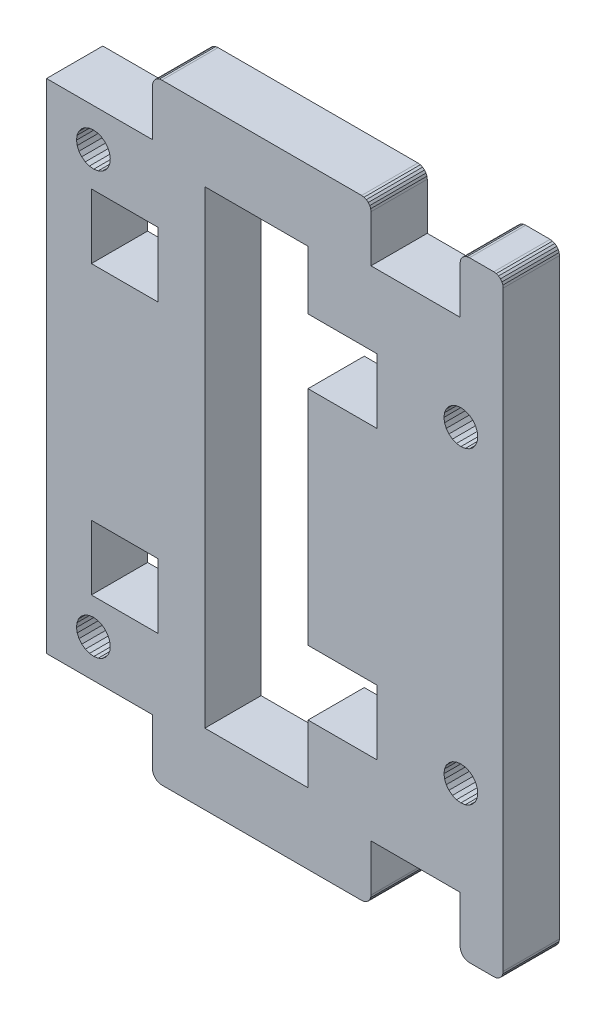
from build123d import *

# Parameters (mm, degrees)
SKETCH1_W           = 7.1
SKETCH1_H           = 6.9
BOSS_EXTRUDE1_DEPTH = 6


with BuildPart() as part:
    # Sketch1 → Boss-Extrude1 (new body)
    with BuildSketch(Plane.XY):
        Polygon((-358.994880286, -293.50655928), (-358.753699331, -293.406658857), (-358.494880286, -293.372584684), (-355.895187501, -293.372584684), (-355.636368456, -293.406658857), (-355.395187501, -293.50655928), (-355.18808072, -293.665477903), (-355.029162097, -293.872584684), (-354.929261675, -294.113765639), (-354.895187501, -294.372584684), (-354.899121361, -357.473371332), (-354.933365099, -357.732036876), (-355.033357982, -357.973038786), (-355.192292447, -358.179969532), (-355.399348154, -358.338741166), (-355.640428649, -358.438544435), (-355.899121051, -358.472584684), (-358.493457382, -358.472584684), (-358.752276427, -358.43851051), (-358.993457382, -358.338610088), (-359.200564163, -358.179691465), (-359.359482786, -357.972584684), (-359.459383208, -357.731403729), (-359.493457382, -357.472584684), (-359.493457382, -352.472584684), (-368.993457382, -352.472584684), (-368.993457382, -357.472584684), (-369.027531556, -357.731403729), (-369.127431978, -357.972584684), (-369.286350601, -358.179691465), (-369.493457382, -358.338610088), (-369.734638337, -358.43851051), (-369.993457382, -358.472584684), (-391.293457382, -358.472584684), (-391.552276427, -358.43851051), (-391.793457382, -358.338610088), (-392.000564163, -358.179691465), (-392.159482786, -357.972584684), (-392.259383208, -357.731403729), (-392.293457382, -357.472584684), (-392.293457382, -352.472584684), (-403.593457382, -352.472584684), (-403.593457382, -299.372584684), (-392.293457382, -299.372584684), (-392.293457382, -294.372584684), (-392.259383208, -294.113765639), (-392.159482786, -293.872584684), (-392.000564163, -293.665477903), (-391.793457382, -293.50655928), (-391.552276427, -293.406658857), (-391.293457382, -293.372584684), (-369.993457382, -293.372584684), (-369.734638337, -293.406658857), (-369.493457382, -293.50655928), (-369.286350601, -293.665477903), (-369.127431978, -293.872584684), (-369.027531556, -294.113765639), (-368.993457382, -294.372584684), (-368.993457382, -299.372584684), (-359.494880286, -299.372584684), (-359.494880286, -294.372584684), (-359.460806112, -294.113765639), (-359.36090569, -293.872584684), (-359.201987067, -293.665477903), align=None)
        Polygon((-357.610920971, -342.372584684), (-357.672254484, -342.838458965), (-357.852075244, -343.272584684), (-358.138128765, -343.64537689), (-358.510920971, -343.931430411), (-358.94504669, -344.111251171), (-359.410920971, -344.172584684), (-359.876795252, -344.111251171), (-360.310920971, -343.931430411), (-360.683713177, -343.64537689), (-360.969766698, -343.272584684), (-361.149587458, -342.838458965), (-361.210920971, -342.372584684), (-361.149587458, -341.906710403), (-360.969766698, -341.472584684), (-360.683713177, -341.099792478), (-360.310920971, -340.813738957), (-359.876795252, -340.633918196), (-359.410920971, -340.572584684), (-358.94504669, -340.633918196), (-358.510920971, -340.813738957), (-358.138128765, -341.099792478), (-357.852075244, -341.472584684), (-357.672254484, -341.906710403), align=None, mode=Mode.SUBTRACT)
        Polygon((-397.058387805, -347.482605219), (-396.867409445, -347.911939484), (-396.7940584, -348.376073376), (-396.843333421, -348.843376937), (-397.011876498, -349.282004201), (-397.288201699, -349.662063445), (-397.653477917, -349.95765426), (-398.082812183, -350.148632621), (-398.546946075, -350.221983666), (-399.014249636, -350.172708645), (-399.4528769, -350.004165568), (-399.832936144, -349.727840367), (-400.128526959, -349.362564149), (-400.319505319, -348.933229883), (-400.392856365, -348.469095991), (-400.343581343, -348.00179243), (-400.175038266, -347.563165166), (-399.898713066, -347.183105922), (-399.533436847, -346.887515107), (-399.104102582, -346.696536747), (-398.63996869, -346.623185701), (-398.172665129, -346.672460723), (-397.734037865, -346.8410038), (-397.35397862, -347.117329), align=None, mode=Mode.SUBTRACT)
        with Locations((-395.260918473, -310.622584684)):
            Rectangle(SKETCH1_W, SKETCH1_H, mode=Mode.SUBTRACT)
        Polygon((-375.710923469, -337.772584684), (-368.342459311, -337.772584684), (-368.342459311, -344.672584684), (-375.710923469, -344.672584684), (-375.710923469, -350.922574533), (-386.710918473, -350.922574533), (-386.710918473, -300.922594835), (-375.710923469, -300.922594835), (-375.710923469, -307.172584684), (-368.342459311, -307.172584684), (-368.342459311, -314.072584684), (-375.710923469, -314.072584684), align=None, mode=Mode.SUBTRACT)
        Polygon((-358.138128765, -310.74537689), (-358.510920971, -311.031430411), (-358.94504669, -311.211251171), (-359.410920971, -311.272584684), (-359.876795252, -311.211251171), (-360.310920971, -311.031430411), (-360.683713177, -310.74537689), (-360.969766698, -310.372584684), (-361.149587458, -309.938458965), (-361.210920971, -309.472584684), (-361.149587458, -309.006710403), (-360.969766698, -308.572584684), (-360.683713177, -308.199792478), (-360.310920971, -307.913738957), (-359.876795252, -307.733918196), (-359.410920971, -307.672584684), (-358.94504669, -307.733918196), (-358.510920971, -307.913738957), (-358.138128765, -308.199792478), (-357.852075244, -308.572584684), (-357.672254484, -309.006710403), (-357.610920971, -309.472584684), (-357.672254484, -309.938458965), (-357.852075244, -310.372584684), align=None, mode=Mode.SUBTRACT)
        Polygon((-400.321176702, -303.927546021), (-400.392999705, -303.463173217), (-400.342186872, -302.99603437), (-400.172201015, -302.557964223), (-399.894626388, -302.178816531), (-399.528379244, -301.884429584), (-399.09841872, -301.694865364), (-398.634045915, -301.623042361), (-398.166907069, -301.673855193), (-397.728836921, -301.843841051), (-397.34968923, -302.121415678), (-397.055302282, -302.487662822), (-396.865738063, -302.917623346), (-396.79391506, -303.381996151), (-396.844727892, -303.849134997), (-397.014713749, -304.287205145), (-397.292288376, -304.666352836), (-397.65853552, -304.960739784), (-398.088496044, -305.150304003), (-398.552868849, -305.222127006), (-399.020007696, -305.171314174), (-399.458077843, -305.001328317), (-399.837225535, -304.72375369), (-400.131612482, -304.357506546), align=None, mode=Mode.SUBTRACT)
        with Locations((-395.260918473, -341.222584684)):
            Rectangle(SKETCH1_W, SKETCH1_H, mode=Mode.SUBTRACT)
    extrude(amount=BOSS_EXTRUDE1_DEPTH)


solid = part.part
